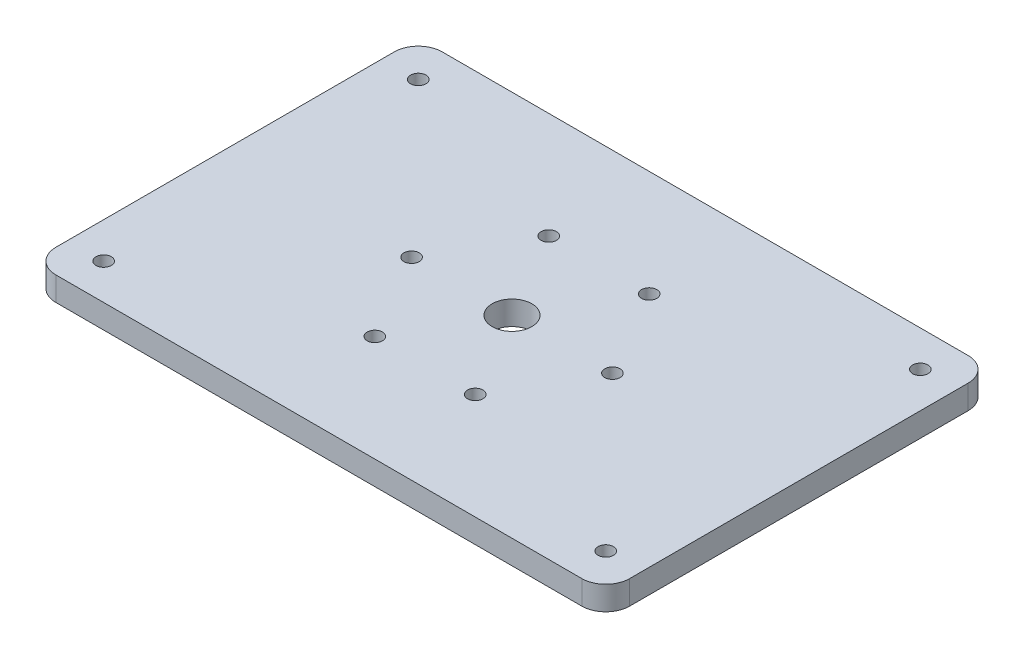
from build123d import *

# Parameters (mm, degrees)
SKETCH1_W           = 120
SKETCH1_H           = 80.79
SKETCH1_R           = 1.6
SKETCH1_R_2         = 4.15
BOSS_EXTRUDE1_DEPTH = 5
SKETCH2_R           = 1.6
CUT_EXTRUDE1_DEPTH  = 6
FILLET1_R           = 5


with BuildPart() as part:
    # Sketch1 → Boss-Extrude1 (new body)
    with BuildSketch(Plane(origin=(0, 0, 0), x_dir=(1, 0, 0), z_dir=(0, 1, 0))):
        with Locations((60, 40.395)):
            Rectangle(SKETCH1_W, SKETCH1_H)
        with Locations((39, 40.395)):
            Circle(SKETCH1_R, mode=Mode.SUBTRACT)
        with Locations((49.5, 58.581533479)):
            Circle(SKETCH1_R, mode=Mode.SUBTRACT)
        with Locations((70.5, 58.581533479)):
            Circle(SKETCH1_R, mode=Mode.SUBTRACT)
        with Locations((81, 40.395)):
            Circle(SKETCH1_R, mode=Mode.SUBTRACT)
        with Locations((60, 40.395)):
            Circle(SKETCH1_R_2, mode=Mode.SUBTRACT)
        with Locations((70.5, 22.208466521)):
            Circle(SKETCH1_R, mode=Mode.SUBTRACT)
        with Locations((49.5, 22.208466521)):
            Circle(SKETCH1_R, mode=Mode.SUBTRACT)
    extrude(amount=BOSS_EXTRUDE1_DEPTH)

    # Sketch2 → Cut-Extrude1 (cut, through all)
    with BuildSketch(Plane(origin=(0, 5, 0), x_dir=(1, 0, 0), z_dir=(0, 1, 0))):
        with Locations((7.5, 73.29)):
            Circle(SKETCH2_R)
        with Locations((7.5, 7.5)):
            Circle(SKETCH2_R)
        with Locations((112.5, 73.29)):
            Circle(SKETCH2_R)
        with Locations((112.5, 7.5)):
            Circle(SKETCH2_R)
    extrude(amount=-CUT_EXTRUDE1_DEPTH, mode=Mode.SUBTRACT)

    # Fillet1
    fillet1_edges = [part.edges().sort_by_distance(p)[0] for p in [
        (0, 2.5, -80.79),
        (120, 2.5, -80.79),
        (120, 2.5, 0),
        (0, 2.5, 0),
    ]]
    fillet(fillet1_edges, radius=FILLET1_R)


solid = part.part
